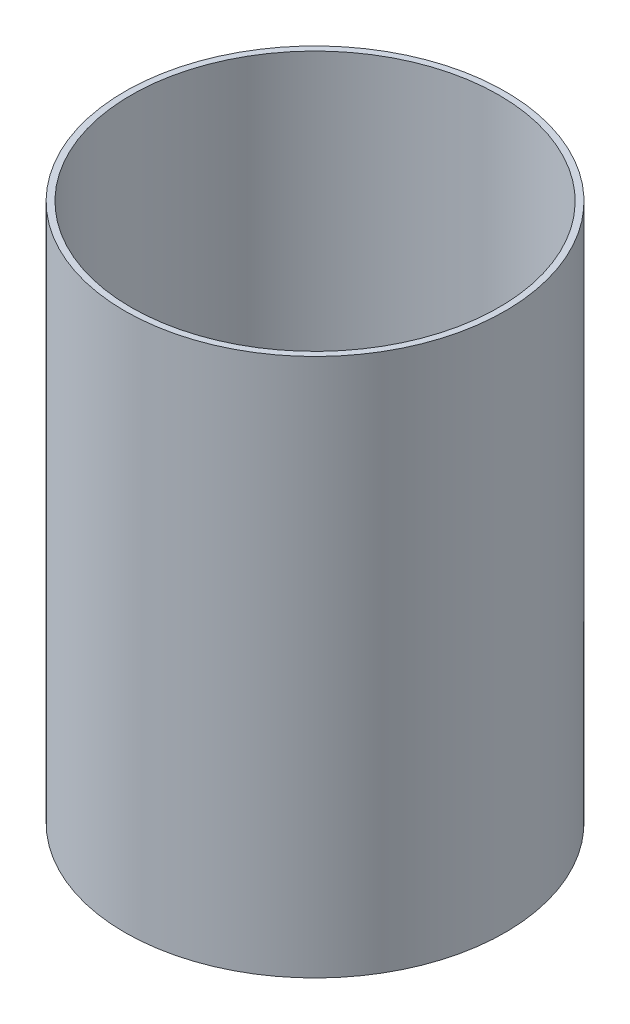
from build123d import *

# Parameters (mm, degrees)
SKETCH1_R               = 92.71
SKETCH1_R_2             = 53.975
TOP_OF_HATCH_DEPTH      = 3.302
SKETCH2_R               = 92.71
SKETCH2_R_2             = 89.662
HATCH_BODY_DEPTH        = 259.08
SKETCH3_R               = 13.97
CHARGE_TUBE_HOLES_DEPTH = 3.302
SKETCH4_R               = 3.81
BOLT_HOLES_DEPTH        = 263.382
SKETCH_5_R              = 5.08
ANTENNA_HOLES_DEPTH     = 263.382


with BuildPart() as part:
    # Sketch1 → Top of Hatch (new body)
    with BuildSketch(Plane(origin=(0, 0, 0), x_dir=(1, 0, 0), z_dir=(0, 1, 0))):
        Circle(SKETCH1_R)
        Circle(SKETCH1_R_2, mode=Mode.SUBTRACT)
    extrude(amount=TOP_OF_HATCH_DEPTH)

    # Sketch2 → Hatch Body (add)
    with BuildSketch(Plane(origin=(0, 3.302, 0), x_dir=(1, 0, 0), z_dir=(0, 1, 0))):
        Circle(SKETCH2_R)
        Circle(SKETCH2_R_2, mode=Mode.SUBTRACT)
    extrude(amount=HATCH_BODY_DEPTH)

    # Sketch3 → Charge Tube Holes (cut)
    with BuildSketch(Plane.XZ):
        with Locations((-75.565, 0)):
            Circle(SKETCH3_R)
        with Locations((75.565, 0)):
            Circle(SKETCH3_R)
    extrude(amount=-CHARGE_TUBE_HOLES_DEPTH, mode=Mode.SUBTRACT)

    # Sketch4 → Bolt Holes (cut, through all)
    with BuildSketch(Plane.XZ):
        with Locations((38.1, 65.991135768)):
            Circle(SKETCH4_R)
        with Locations((-38.1, 65.991135768)):
            Circle(SKETCH4_R)
        with Locations((-38.1, -65.991135768)):
            Circle(SKETCH4_R)
        with Locations((38.1, -65.991135768)):
            Circle(SKETCH4_R)
    extrude(amount=-BOLT_HOLES_DEPTH, mode=Mode.SUBTRACT)

    # Sketch 5 → Antenna Holes (cut, through all)
    with BuildSketch(Plane.XZ):
        with Locations((-26.112352144, 57.324838678)):
            Circle(SKETCH_5_R)
        with Locations((9.193647856, 61.033450854)):
            Circle(SKETCH_5_R)
    extrude(amount=-ANTENNA_HOLES_DEPTH, mode=Mode.SUBTRACT)


solid = part.part
